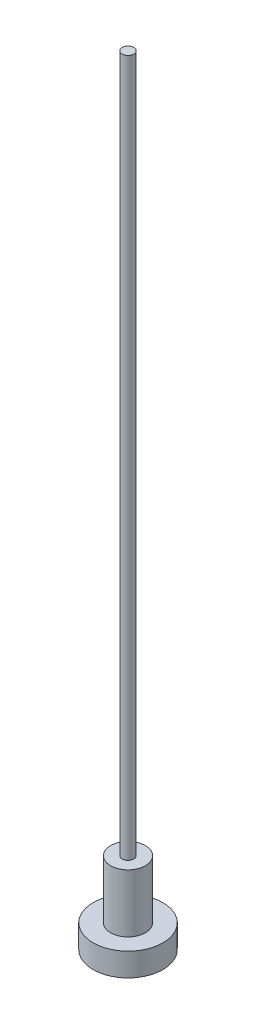
from build123d import *

# Parameters (mm, degrees)
SKETCH2_R           = 1.5
BOSS_EXTRUDE1_DEPTH = 5
SKETCH3_R           = 0.5
BOSS_EXTRUDE2_DEPTH = 60
SKETCH4_R           = 3
BOSS_EXTRUDE3_DEPTH = 2


with BuildPart() as part:
    # Sketch2 → Boss-Extrude1 (new body)
    with BuildSketch(Plane(origin=(0, 0, 0), x_dir=(1, 0, 0), z_dir=(0, 1, 0))):
        Circle(SKETCH2_R)
    extrude(amount=BOSS_EXTRUDE1_DEPTH)

    # Sketch3 → Boss-Extrude2 (add)
    with BuildSketch(Plane(origin=(0, 5, 0), x_dir=(1, 0, 0), z_dir=(0, 1, 0))):
        Circle(SKETCH3_R)
    extrude(amount=BOSS_EXTRUDE2_DEPTH)

    # Sketch4 → Boss-Extrude3 (add)
    with BuildSketch(Plane.XZ):
        Circle(SKETCH4_R)
    extrude(amount=BOSS_EXTRUDE3_DEPTH)


solid = part.part
